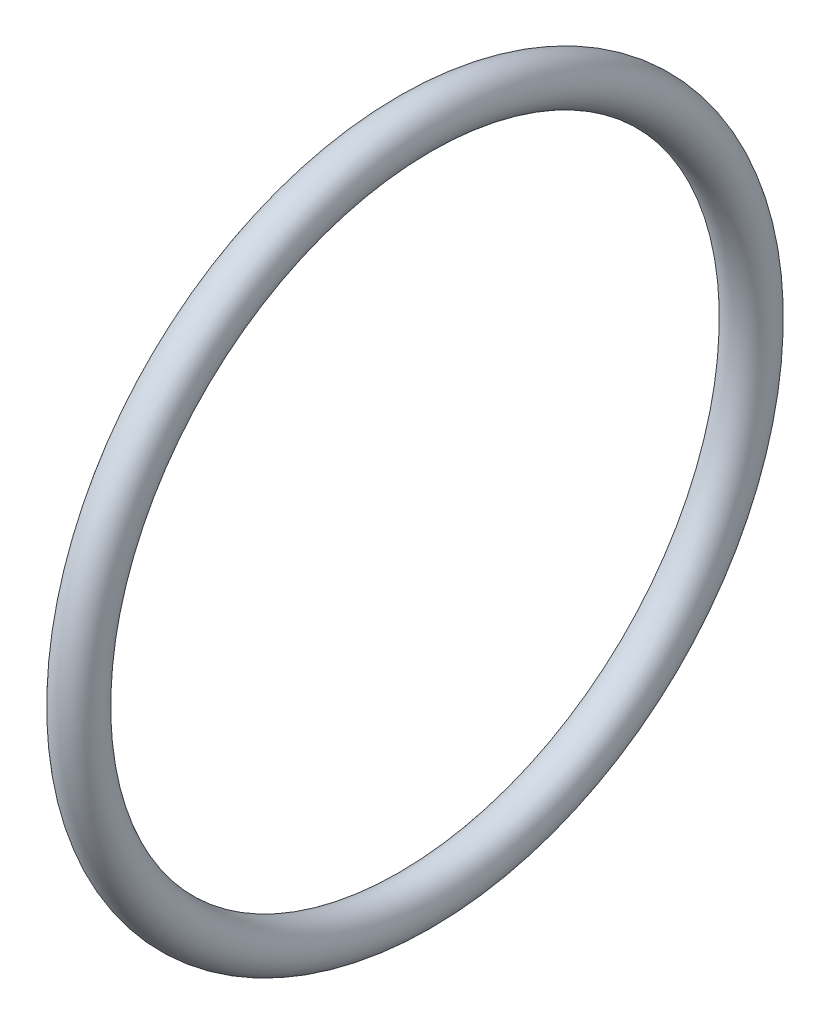
from build123d import *

# Parameters (mm, degrees)
CROQUIS1_R = 1.190625


with BuildPart() as part:
    # Barrer1: sweep along a path in Croquis2
    with BuildLine(Plane(origin=(0, 0, 0), x_dir=(0, 0, -1), z_dir=(1, 0, 0))) as barrer1_path:
        CenterArc((0, 0), 17.6784, 0, 360)
    # Croquis1 → Barrer1 (sweep)
    with BuildSketch(Plane.XY):
        with Locations((0, -17.6784)):
            Circle(CROQUIS1_R)
    sweep(path=barrer1_path.line)


solid = part.part
